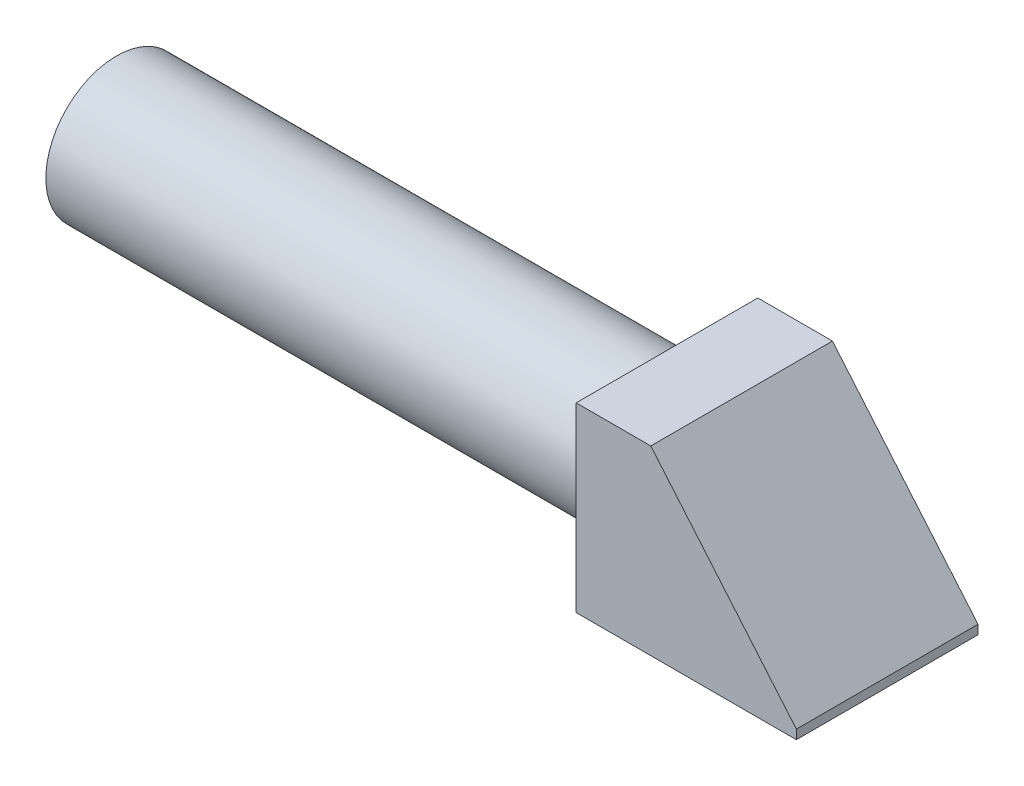
from build123d import *

# Parameters (mm, degrees)
SKETCH1_R           = 3.85
BOSS_EXTRUDE1_DEPTH = 30
SKETCH2_R           = 3.85
SKETCH2_R_2         = 3.25
CUT_EXTRUDE1_DEPTH  = 1
SKETCH3_W           = 9.9
SKETCH3_H           = 9.9
BOSS_EXTRUDE2_DEPTH = 12
CUT_EXTRUDE2_DEPTH  = 12


with BuildPart() as part:
    # Sketch1 → Boss-Extrude1 (new body)
    with BuildSketch(Plane(origin=(0, 0, 0), x_dir=(0, 0, -1), z_dir=(1, 0, 0))):
        Circle(SKETCH1_R)
    extrude(amount=BOSS_EXTRUDE1_DEPTH)

    # Sketch2 → Cut-Extrude1 (cut)
    with BuildSketch(Plane(origin=(30, 0, 0), x_dir=(0, 0, -1), z_dir=(1, 0, 0))):
        Circle(SKETCH2_R)
        Circle(SKETCH2_R_2, mode=Mode.SUBTRACT)
    extrude(amount=-CUT_EXTRUDE1_DEPTH, mode=Mode.SUBTRACT)

    # Sketch3 → Boss-Extrude2 (add)
    with BuildSketch(Plane(origin=(30, 0, 0), x_dir=(0, 0, -1), z_dir=(1, 0, 0))):
        Rectangle(SKETCH3_W, SKETCH3_H)
    extrude(amount=BOSS_EXTRUDE2_DEPTH)

    # Sketch4 → Cut-Extrude2 (cut)
    with BuildSketch(Plane.XY.offset(4.95)):
        Polygon((34.067156878, 4.95), (42, -4.45), (42, 4.95), align=None)
    extrude(amount=-CUT_EXTRUDE2_DEPTH, mode=Mode.SUBTRACT)


solid = part.part
